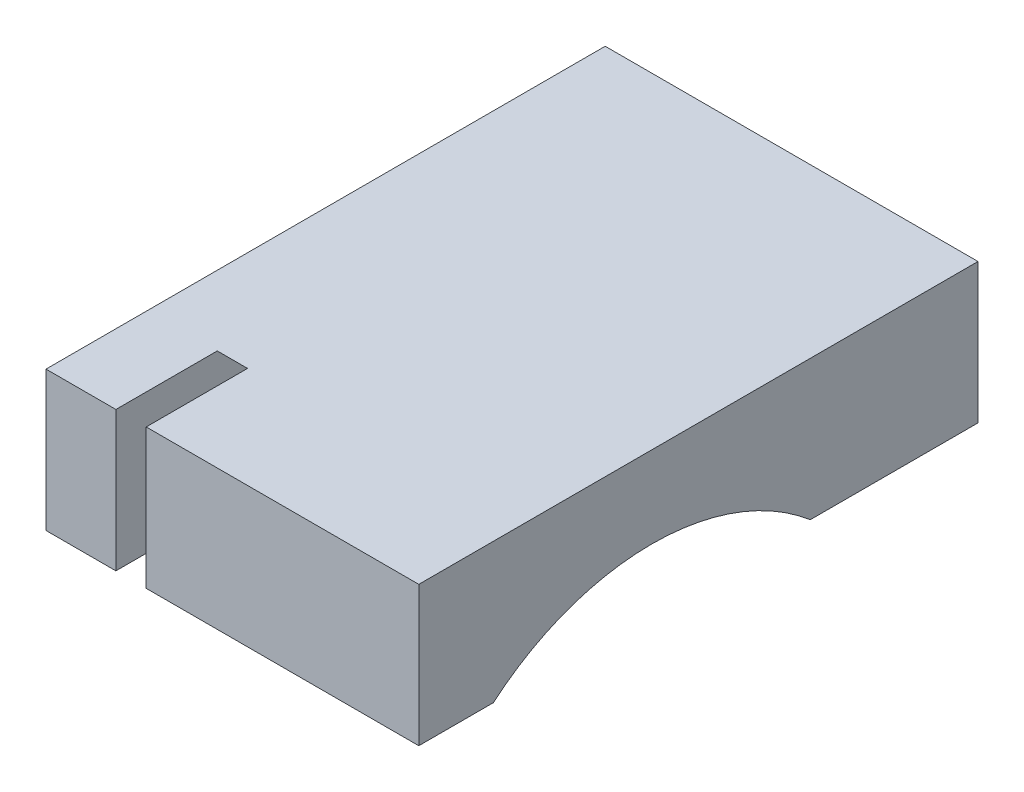
from build123d import *

# Parameters (mm, degrees)
SKETCH_1_W          = 24
SKETCH_1_H          = 6
EXTRUDE_1_DEPTH     = 16
CUT_EXTRUDE_1_DEPTH = 13
CUT_EXTRUDE_START   = -11.7
CUT_EXTRUDE_6_DEPTH = 1.3


with BuildPart() as part:
    # Эскиз1 → Бобышка-Вытянуть1 (new body)
    with BuildSketch(Plane(origin=(0, 0, 0), x_dir=(0, 0, -1), z_dir=(1, 0, 0))):
        with Locations((12, 3)):
            Rectangle(SKETCH_1_W, SKETCH_1_H)
    extrude(amount=EXTRUDE_1_DEPTH)

    # Эскиз2 → Вырез-Вытянуть1 (cut)
    with BuildSketch(Plane(origin=(16, 0, 0), x_dir=(0, 0, -1), z_dir=(1, 0, 0))):
        with BuildLine():
            ThreePointArc((16.800735254, 0), (10, 2.5), (3.199264746, 0))
            Line((3.199264746, 0), (16.800735254, 0))
        make_face()
    extrude(amount=-CUT_EXTRUDE_1_DEPTH, mode=Mode.SUBTRACT)

    # Эскиз3 → Вырез-Вытянуть6 (cut)
    with BuildSketch(Plane(origin=(16, 0, 0), x_dir=(0, 0, -1), z_dir=(1, 0, 0)).offset(CUT_EXTRUDE_START)):
        with BuildLine():
            Line((11.871529868, 2.331862173), (4.350732789, 6))
            Line((4.350732789, 6), (0, 6))
            Line((0, 6), (0, 0))
            Line((0, 0), (3.199264746, 0))
            ThreePointArc((3.199264746, 0), (7.273525769, 2.139839164), (11.871529868, 2.331862173))
        make_face()
    extrude(amount=-CUT_EXTRUDE_6_DEPTH, mode=Mode.SUBTRACT)


solid = part.part
